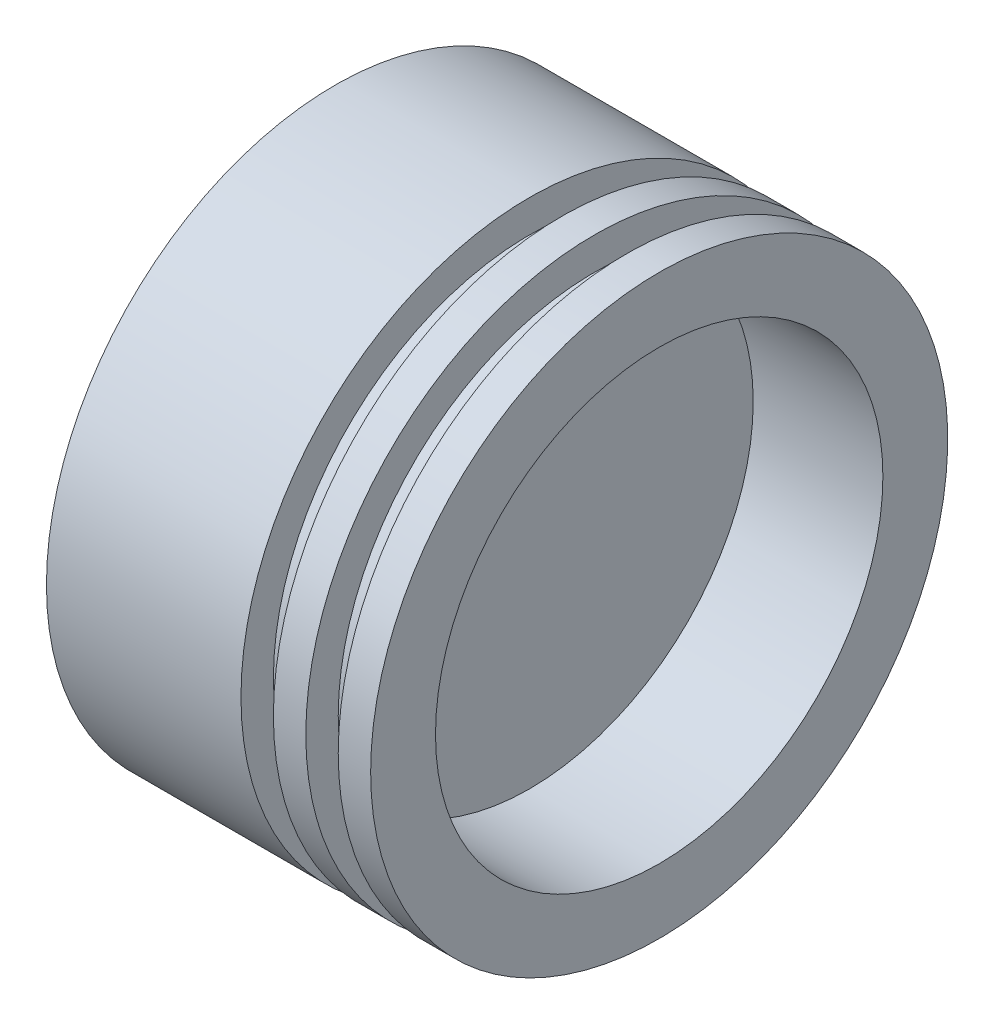
from build123d import *


with BuildPart() as part:
    # Sketch1 → Revolve1 (revolve)
    with BuildSketch(Plane.XY):
        Polygon((0, 0), (0, 44.5), (30, 44.5), (30, 39.5), (35, 39.5), (35, 44.5), (40, 44.5), (40, 39.5), (45, 39.5), (45, 44.5), (50, 44.5), (50, 34.5), (30, 34.5), (30, 0), align=None)
    revolve(axis=Axis((0, 0, 0), (1, 0, 0)))


solid = part.part
